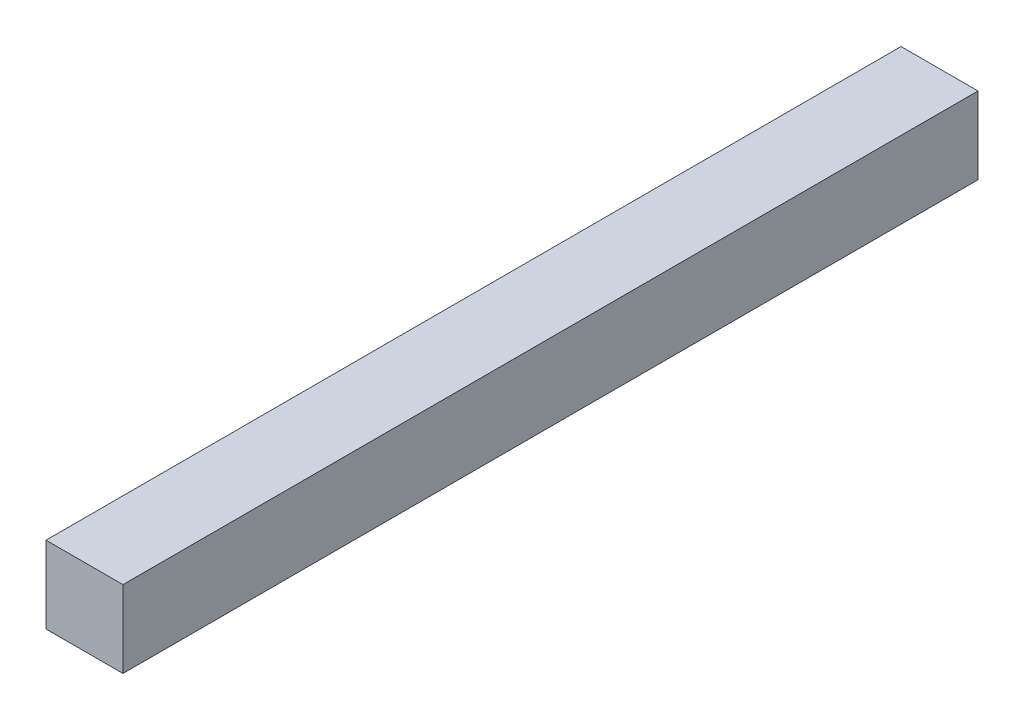
from build123d import *

# Parameters (mm, degrees)
ESQUISSE1_W      = 18
ESQUISSE1_H      = 18
EXTRUSION1_DEPTH = 200


with BuildPart() as part:
    # Esquisse1 → Extrusion1 (new body)
    with BuildSketch(Plane.XY):
        with Locations((9, 9)):
            Rectangle(ESQUISSE1_W, ESQUISSE1_H)
    extrude(amount=-EXTRUSION1_DEPTH)


solid = part.part
